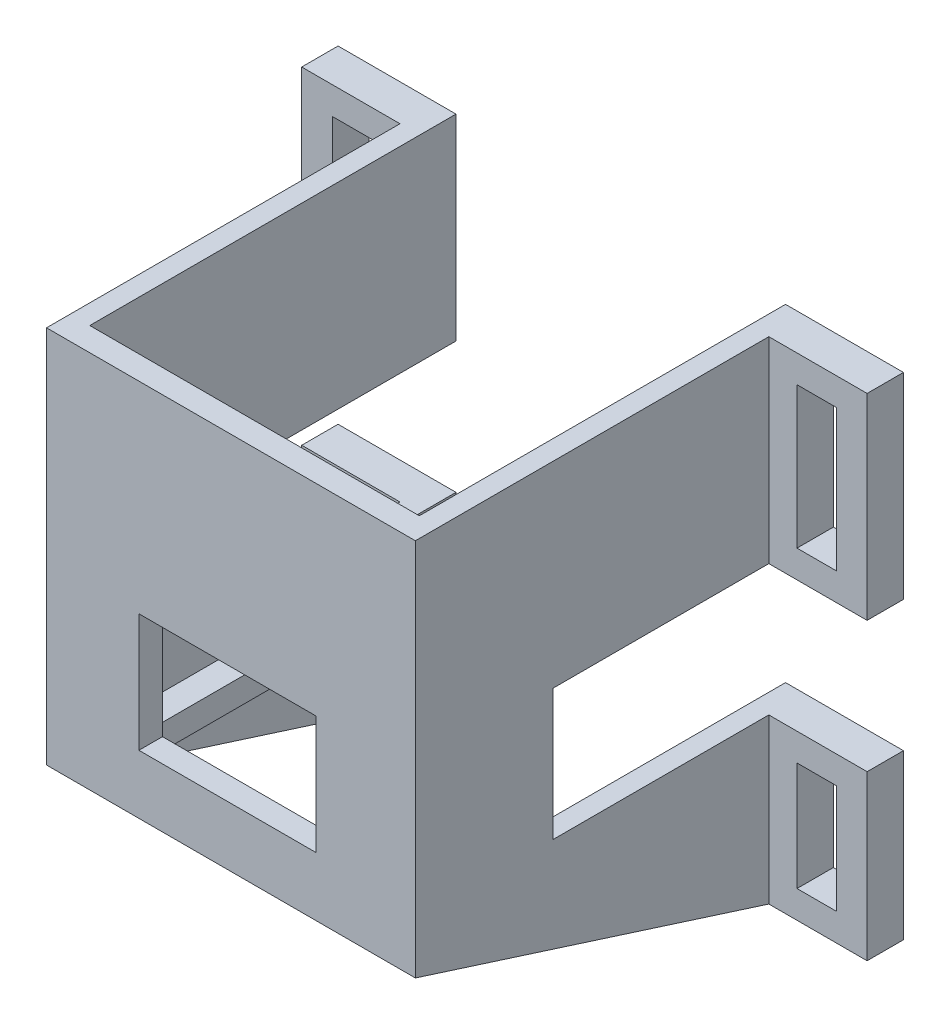
from build123d import *

# Parameters (mm, degrees)
SKETCH1_W               = 27
SKETCH1_H               = 18.05
SKETCH1_W_2             = 15
SKETCH1_H_2             = 30
SKETCH1_H_3             = 25
BOSS_EXTRUDE1_DEPTH     = 59.5
SKETCH3_W               = 15
SKETCH3_H               = 75
CUT_EXTRUDE2_DEPTH      = 53.95
SKETCH4_W               = 6
SKETCH4_H               = 16.6
SKETCH4_H_2             = 21.6
CUT_EXTRUDE3_DEPTH      = 10
CUT_EXTRUDE4_DEPTH      = 1
CUT_EXTRUDE4_DEPTH_BACK = 54
CUT_EXTRUDE5_DEPTH      = 1
CUT_EXTRUDE5_DEPTH_BACK = 17.2
SKETCH8_W               = 42.3
SKETCH8_H               = 3.8
CUT_EXTRUDE6_DEPTH      = 51.9
CUT_EXTRUDE7_DEPTH      = 16
CUT_EXTRUDE7_DEPTH_BACK = 60
CUT_EXTRUDE8_DEPTH      = 60


with BuildPart() as part:
    # Sketch1 → Boss-Extrude1 (new body)
    with BuildSketch(Plane.XY):
        Polygon((71.3, 0), (15, 0), (15, 25), (15, 75), (71.3, 75), align=None)
        with Locations((42.6, 35.225)):
            Rectangle(SKETCH1_W, SKETCH1_H, mode=Mode.SUBTRACT)
        with Locations((78.8, 60)):
            Rectangle(SKETCH1_W_2, SKETCH1_H_2)
        with Locations((78.8, 12.5)):
            Rectangle(SKETCH1_W_2, SKETCH1_H_3)
        with Locations((7.5, 12.5)):
            Rectangle(SKETCH1_W_2, SKETCH1_H_3)
        with Locations((7.5, 60)):
            Rectangle(SKETCH1_W_2, SKETCH1_H_2)
    extrude(amount=BOSS_EXTRUDE1_DEPTH)

    # Sketch3 → Cut-Extrude2 (cut)
    with BuildSketch(Plane.XY.offset(59.5)):
        with Locations((7.5, 37.5)):
            Rectangle(SKETCH3_W, SKETCH3_H)
        with Locations((78.8, 37.5)):
            Rectangle(SKETCH3_W, SKETCH3_H)
    extrude(amount=-CUT_EXTRUDE2_DEPTH, mode=Mode.SUBTRACT)

    # Sketch4 → Cut-Extrude3 (cut)
    with BuildSketch(Plane.XY.offset(5.55)):
        with Locations((7.7, 12.5)):
            Rectangle(SKETCH4_W, SKETCH4_H)
        with Locations((7.7, 60)):
            Rectangle(SKETCH4_W, SKETCH4_H_2)
        with Locations((78.6, 60)):
            Rectangle(SKETCH4_W, SKETCH4_H_2)
        with Locations((78.6, 12.5)):
            Rectangle(SKETCH4_W, SKETCH4_H)
    extrude(amount=-CUT_EXTRUDE3_DEPTH, mode=Mode.SUBTRACT)

    # Sketch6 → Cut-Extrude4 (cut, two sides)
    with BuildSketch(Plane(origin=(0, 75, 0), x_dir=(1, 0, 0), z_dir=(0, 1, 0))) as cut_extrude4_sk:
        Polygon((18, 191.164455675), (18, 0), (18, -55.9), (68.3, -55.9), (68.3, 0), (68.3, 191.164455675), (68.3, 573.493367025), (18, 573.493367025), align=None)
    extrude(amount=CUT_EXTRUDE4_DEPTH, mode=Mode.SUBTRACT)
    extrude(cut_extrude4_sk.sketch, amount=-CUT_EXTRUDE4_DEPTH_BACK, mode=Mode.SUBTRACT)

    # Sketch7 → Cut-Extrude5 (cut, two sides)
    with BuildSketch(Plane.XZ) as cut_extrude5_sk:
        Polygon((18, -191.164455675), (18, 0), (18, 55.9), (68.3, 55.9), (68.3, 0), (68.3, -191.164455675), (68.3, -573.493367025), (18, -573.493367025), align=None)
    extrude(amount=CUT_EXTRUDE5_DEPTH, mode=Mode.SUBTRACT)
    extrude(cut_extrude5_sk.sketch, amount=-CUT_EXTRUDE5_DEPTH_BACK, mode=Mode.SUBTRACT)

    # Sketch8 → Cut-Extrude6 (cut)
    with BuildSketch(Plane(origin=(0, 0, 0), x_dir=(-1, 0, 0), z_dir=(0, 0, -1))):
        with Locations((-43.15, 19.1)):
            Rectangle(SKETCH8_W, SKETCH8_H)
    extrude(amount=-CUT_EXTRUDE6_DEPTH, mode=Mode.SUBTRACT)

    # Sketch9 → Cut-Extrude7 (cut, two sides)
    with BuildSketch(Plane.ZY.offset(-15)) as cut_extrude7_sk:
        Polygon((-165.43809057, 45), (0, 45), (38.5, 45), (38.5, 25), (0, 25), (-165.43809057, 25), (-496.31427171, 25), (-496.31427171, 45), align=None)
    extrude(amount=CUT_EXTRUDE7_DEPTH, mode=Mode.SUBTRACT)
    extrude(cut_extrude7_sk.sketch, amount=-CUT_EXTRUDE7_DEPTH_BACK, mode=Mode.SUBTRACT)

    # Sketch11 → Cut-Extrude8 (cut)
    with BuildSketch(Plane(origin=(71.3, 0, 0), x_dir=(0, 0, -1), z_dir=(1, 0, 0))):
        Polygon((-5.55, 0), (-59.5, 17.2), (-59.5, 0), align=None)
    extrude(amount=-CUT_EXTRUDE8_DEPTH, mode=Mode.SUBTRACT)


solid = part.part
